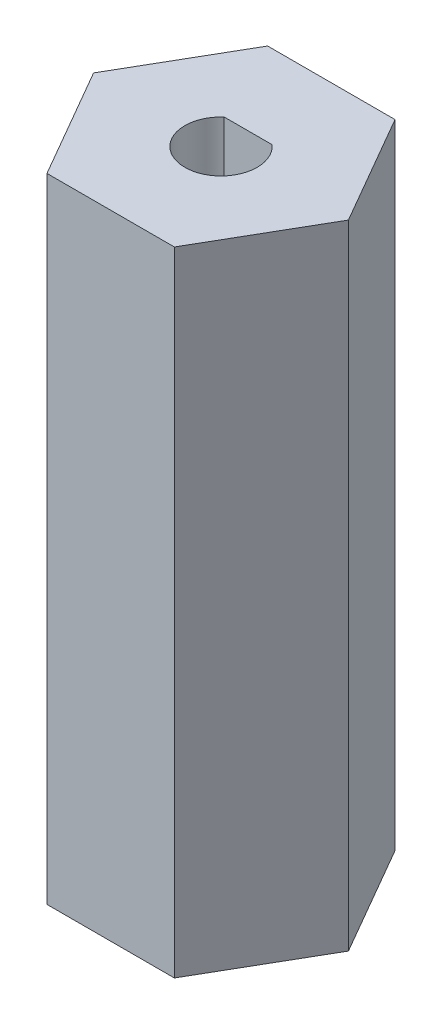
from build123d import *

# Parameters (mm, degrees)
BOSS_EXTRUDE2_DEPTH = 35
SKETCH6_R           = 1.27
CUT_EXTRUDE2_DEPTH  = 21
CUT_EXTRUDE3_DEPTH  = 14


with BuildPart() as part:
    # Sketch1 → Boss-Extrude2 (new body)
    with BuildSketch(Plane(origin=(0, 0, 0), x_dir=(1, 0, 0), z_dir=(0, 1, 0))):
        Polygon((3.521836642, 6.1), (-3.521836642, 6.1), (-7.043673284, 0), (-3.521836642, -6.1), (3.521836642, -6.1), (7.043673284, 0), align=None)
    extrude(amount=BOSS_EXTRUDE2_DEPTH)

    # Sketch6 → Cut-Extrude2 (cut)
    with BuildSketch(Plane.XZ):
        Circle(SKETCH6_R)
    extrude(amount=-CUT_EXTRUDE2_DEPTH, mode=Mode.SUBTRACT)

    # Sketch7 → Cut-Extrude3 (cut)
    with BuildSketch(Plane(origin=(0, 35, 0), x_dir=(1, 0, 0), z_dir=(0, 1, 0))):
        with BuildLine():
            Line((-1.322875656, 1.5), (1.322875656, 1.5))
            ThreePointArc((1.322875656, 1.5), (0, -2), (-1.322875656, 1.5))
        make_face()
    extrude(amount=-CUT_EXTRUDE3_DEPTH, mode=Mode.SUBTRACT)


solid = part.part
